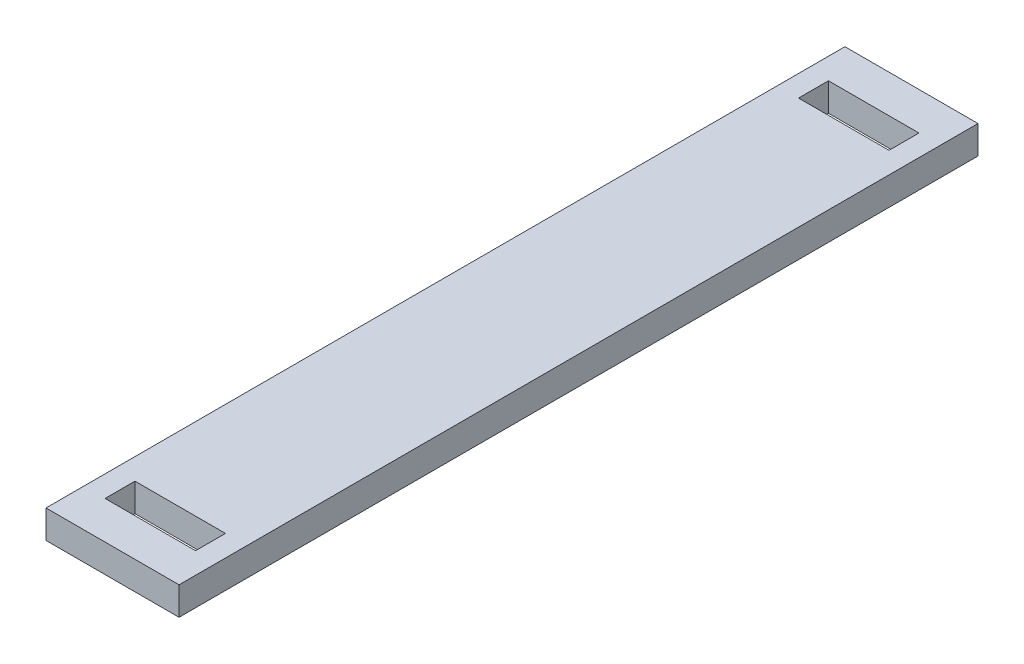
from build123d import *

# Parameters (mm, degrees)
SKETCH1_W           = 30
SKETCH1_H           = 180.1244
BOSS_EXTRUDE1_DEPTH = 6.35
SKETCH2_W           = 20.4
SKETCH2_H           = 6.75
CUT_EXTRUDE1_DEPTH  = 6.35


with BuildPart() as part:
    # Sketch1 → Boss-Extrude1 (new body)
    with BuildSketch(Plane(origin=(0, 0, 0), x_dir=(1, 0, 0), z_dir=(0, 1, 0))):
        Rectangle(SKETCH1_W, SKETCH1_H)
    extrude(amount=BOSS_EXTRUDE1_DEPTH)

    # Sketch2 → Cut-Extrude1 (cut)
    with BuildSketch(Plane(origin=(0, 6.35, 0), x_dir=(1, 0, 0), z_dir=(0, 1, 0))):
        with Locations((0, 78.175)):
            Rectangle(SKETCH2_W, SKETCH2_H)
        with Locations((0, -78.175)):
            Rectangle(SKETCH2_W, SKETCH2_H)
    extrude(amount=-CUT_EXTRUDE1_DEPTH, mode=Mode.SUBTRACT)


solid = part.part
